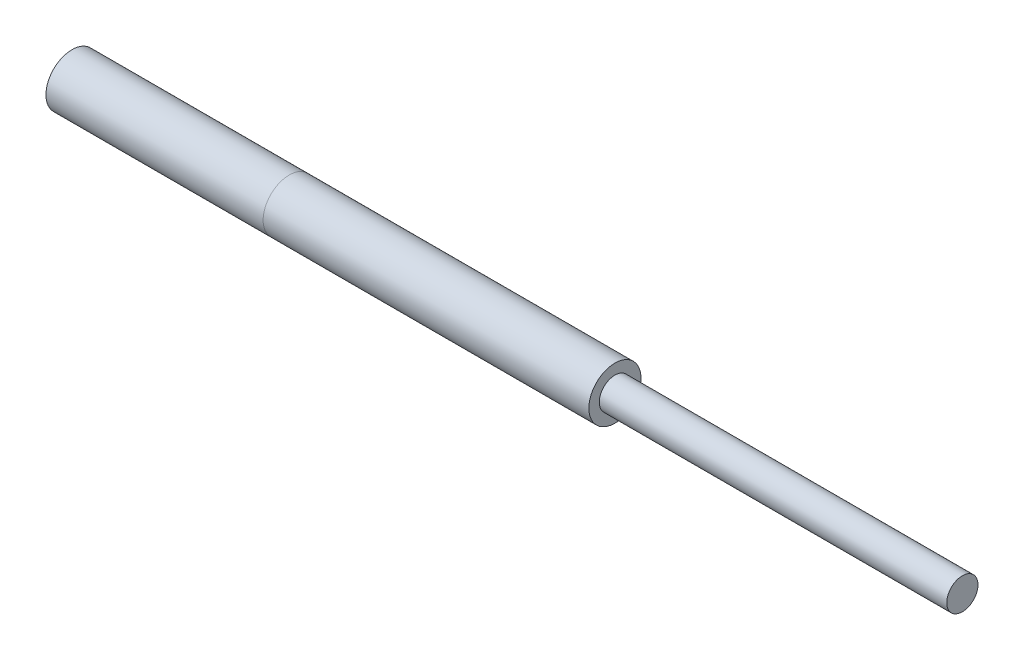
from build123d import *

# Parameters (mm, degrees)
SKETCH1_R           = 30
SKETCH1_R_2         = 20
BOSS_EXTRUDE1_DEPTH = 250
SKETCH2_R           = 30
BOSS_EXTRUDE2_DEPTH = 375
SKETCH3_R           = 18
BOSS_EXTRUDE3_DEPTH = 400


with BuildPart() as part:
    # Sketch1 → Boss-Extrude1 (new body)
    with BuildSketch(Plane(origin=(0, 0, 0), x_dir=(0, 0, -1), z_dir=(1, 0, 0))):
        Circle(SKETCH1_R)
        Circle(SKETCH1_R_2, mode=Mode.SUBTRACT)
    extrude(amount=BOSS_EXTRUDE1_DEPTH)


with BuildPart() as body_2:
    # Sketch2 → Boss-Extrude2 (new body)
    with BuildSketch(Plane(origin=(250, 0, 0), x_dir=(0, 0, -1), z_dir=(1, 0, 0))):
        Circle(SKETCH2_R)
    extrude(amount=BOSS_EXTRUDE2_DEPTH)


with BuildPart() as body_3:
    # Sketch3 → Boss-Extrude3 (new body)
    with BuildSketch(Plane(origin=(625, 0, 0), x_dir=(0, 0, -1), z_dir=(1, 0, 0))):
        Circle(SKETCH3_R)
    extrude(amount=BOSS_EXTRUDE3_DEPTH)


solid = Compound([part.part, body_2.part, body_3.part])
